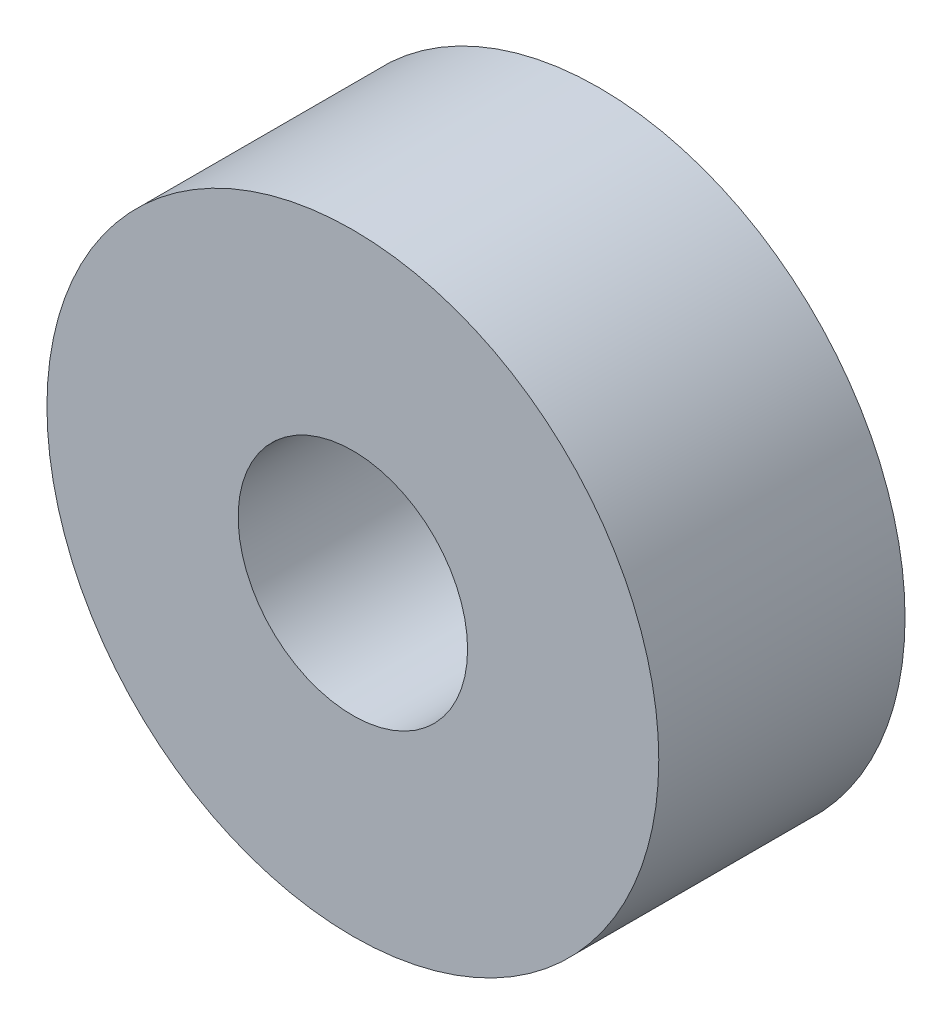
from build123d import *

# Parameters (mm, degrees)
SKETCH1_R           = 4
SKETCH1_R_2         = 1.5
BOSS_EXTRUDE1_DEPTH = 1.61


with BuildPart() as part:
    # Sketch1 → Boss-Extrude1 (new body, symmetric)
    with BuildSketch(Plane.XY):
        Circle(SKETCH1_R)
        Circle(SKETCH1_R_2, mode=Mode.SUBTRACT)
    extrude(amount=BOSS_EXTRUDE1_DEPTH, both=True)


solid = part.part
